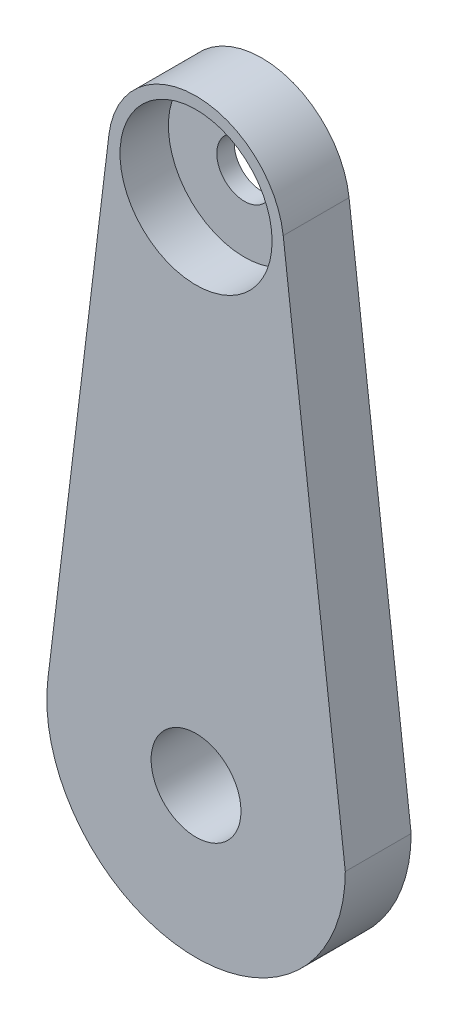
from build123d import *

# Parameters (mm, degrees)
SKETCH1_R           = 11
BOSS_EXTRUDE1_DEPTH = 9.525
SKETCH1_3_R         = 11
BOSS_EXTRUDE2_DEPTH = 2.52476
SKETCH2_R           = 4
CUT_EXTRUDE1_DEPTH  = 2.52476
SKETCH3_R           = 6.5
CUT_EXTRUDE2_DEPTH  = 90.525992455


with BuildPart() as part:
    # Sketch1 → Boss-Extrude1 (new body)
    with BuildSketch(Plane.XY):
        with BuildLine():
            ThreePointArc((12.610334109, 75.166477239), (0.013235783, 86.359993103), (-12.607166653, 75.192758621))
            Line((-12.607166653, 75.192758621), (-21.43218331, 2.605689655))
            ThreePointArc((-21.43218331, 2.605689655), (-1.305232229, -21.550509712), (21.59, 0))
            Line((21.59, 0), (12.610334109, 75.166477239))
        make_face()
        with Locations((0, 73.66)):
            Circle(SKETCH1_R, mode=Mode.SUBTRACT)
    extrude(amount=BOSS_EXTRUDE1_DEPTH)

    # Sketch1_3 → Boss-Extrude2 (add)
    with BuildSketch(Plane.XY):
        with Locations((0, 73.66)):
            Circle(SKETCH1_3_R)
    extrude(amount=BOSS_EXTRUDE2_DEPTH)

    # Sketch2 → Cut-Extrude1 (cut)
    with BuildSketch(Plane.XY.offset(2.52476)):
        with Locations((0, 73.66)):
            Circle(SKETCH2_R)
    extrude(amount=-CUT_EXTRUDE1_DEPTH, mode=Mode.SUBTRACT)

    # Sketch3 → Cut-Extrude2 (cut, through all)
    with BuildSketch(Plane.XY.offset(9.525)):
        Circle(SKETCH3_R)
    extrude(amount=-CUT_EXTRUDE2_DEPTH, mode=Mode.SUBTRACT)


solid = part.part
